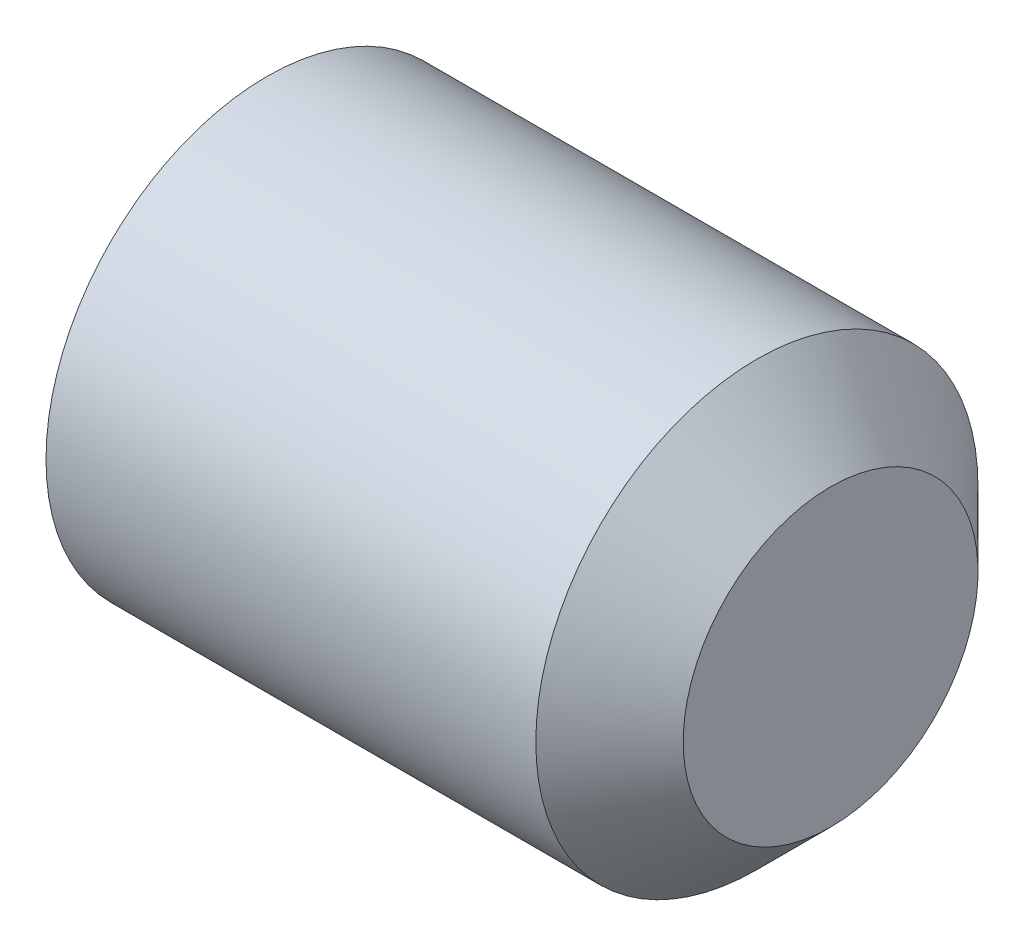
from build123d import *

# Parameters (mm, degrees)
CUT_EXTRUDE1_DEPTH = 1.2


with BuildPart() as part:
    # Sketch1 → Revolve1 (revolve)
    with BuildSketch(Plane.XY):
        Polygon((4, 0), (4, -1), (3.5, -1.5), (0.176957858, -1.5), (0, -1.1935), (0, -0.866025404), (0.5, 0), align=None)
    revolve(axis=Axis((0.5, 0, 0), (1, 0, 0)))

    # Sketch2 → Cut-Extrude1 (cut)
    with BuildSketch(Plane(origin=(0, 0, 0), x_dir=(0, 0, -1), z_dir=(1, 0, 0))):
        Polygon((-0.866025404, 0), (-0.433012702, -0.75), (0.433012702, -0.75), (0.866025404, 0), (0.433012702, 0.75), (-0.433012702, 0.75), align=None)
    extrude(amount=CUT_EXTRUDE1_DEPTH, mode=Mode.SUBTRACT)


solid = part.part
